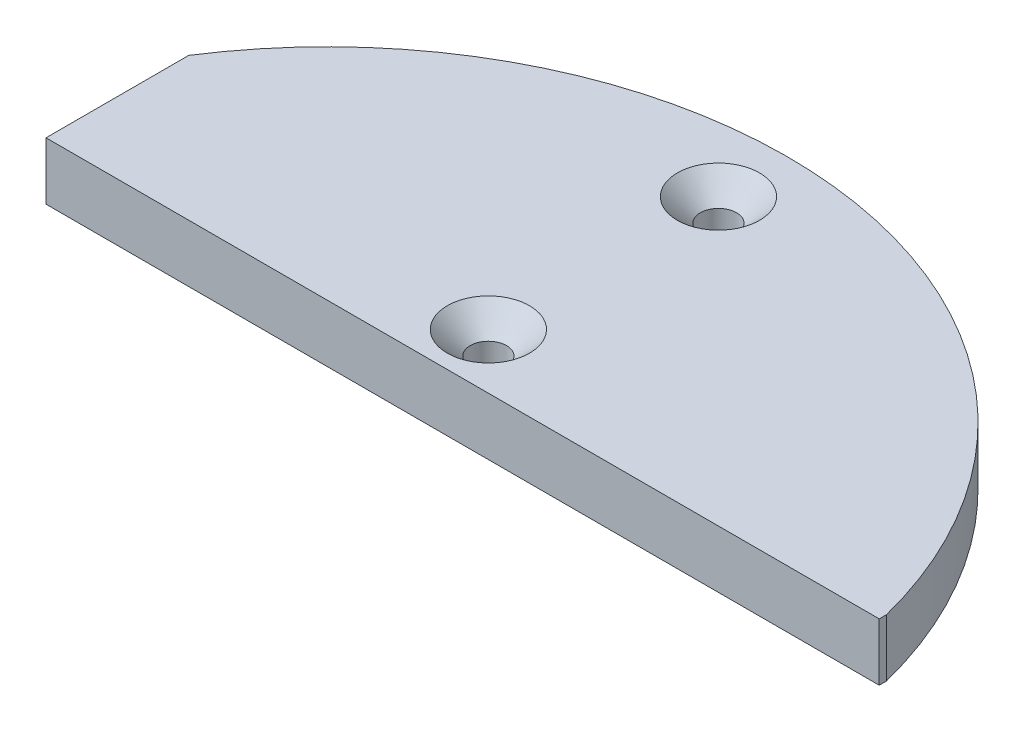
from build123d import *

# Parameters (mm, degrees)
SKETCH1_R           = 2
BOSS_EXTRUDE1_DEPTH = 6.35
CHAMFER1_SIZE       = 2.54


with BuildPart() as part:
    # Sketch1 → Boss-Extrude1 (new body)
    with BuildSketch(Plane(origin=(0, 0, 0), x_dir=(1, 0, 0), z_dir=(0, 1, 0))):
        with BuildLine():
            Line((-42.746, 11.684), (47.586884748, 11.684))
            Line((47.586884748, 11.684), (47.586884748, 17.78))
            ThreePointArc((47.586884748, 17.78), (31.011055518, 40.236232871), (5.073646026, 50.546))
            Line((5.073646026, 50.546), (-5.073646026, 50.546))
            ThreePointArc((-5.073646026, 50.546), (-26.552841725, 43.308043091), (-42.746, 27.448487827))
            Line((-42.746, 27.448487827), (-42.746, 11.684))
        make_face()
        with Locations((0, 17.78)):
            Circle(SKETCH1_R, mode=Mode.SUBTRACT)
        with Locations((0, 43.18)):
            Circle(SKETCH1_R, mode=Mode.SUBTRACT)
        with BuildLine():
            Line((47.586884748, 17.78), (47.586884748, 11.684))
            Line((47.586884748, 11.684), (49.243425186, 11.684))
            Line((49.243425186, 11.684), (49.243425186, 12.478985375))
            ThreePointArc((49.243425186, 12.478985375), (48.487652237, 15.15214772), (47.586884748, 17.78))
        make_face()
        with BuildLine():
            Line((-5.073646026, 50.546), (5.073646026, 50.546))
            ThreePointArc((5.073646026, 50.546), (2.539999948, 50.736460265), (-1.05e-07, 50.8))
            ThreePointArc((-1.05e-07, 50.8), (-2.540000052, 50.73646026), (-5.073646026, 50.546))
        make_face()
    extrude(amount=BOSS_EXTRUDE1_DEPTH)

    # Chamfer1
    chamfer1_edges = [part.edges().sort_by_distance(p)[0] for p in [
        (-2, 6.35, -17.78),
        (-2, 6.35, -43.18),
    ]]
    chamfer(chamfer1_edges, length=CHAMFER1_SIZE)


solid = part.part
